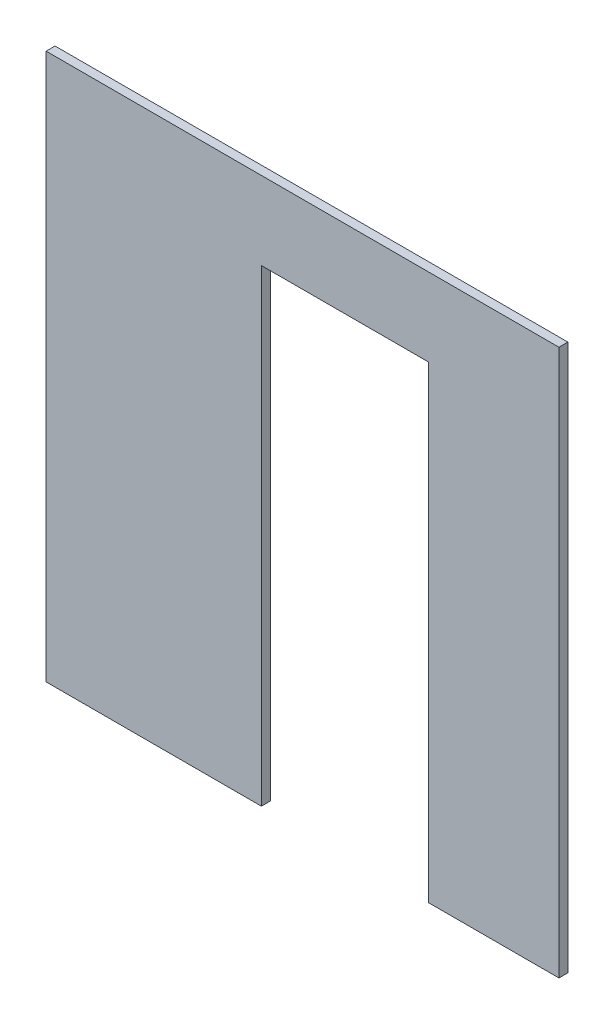
from build123d import *

# Parameters (mm, degrees)
SKETCH1_W               = 2300
SKETCH1_H               = 2450
BOSS_EXTRUDE1_DEPTH     = 40
SKETCH2_W               = 750
SKETCH2_H               = 2100
CUT_EXTRUDE1_DEPTH      = 100
CUT_EXTRUDE1_DEPTH_BACK = 100


with BuildPart() as part:
    # Sketch1 → Boss-Extrude1 (new body)
    with BuildSketch(Plane.XY):
        with Locations((1150, 1225)):
            Rectangle(SKETCH1_W, SKETCH1_H)
    extrude(amount=BOSS_EXTRUDE1_DEPTH)

    # Sketch2 → Cut-Extrude1 (cut, two sides)
    with BuildSketch(Plane.XY) as cut_extrude1_sk:
        with Locations((1340.402049567, 1050)):
            Rectangle(SKETCH2_W, SKETCH2_H)
    extrude(amount=CUT_EXTRUDE1_DEPTH, mode=Mode.SUBTRACT)
    extrude(cut_extrude1_sk.sketch, amount=-CUT_EXTRUDE1_DEPTH_BACK, mode=Mode.SUBTRACT)


solid = part.part
